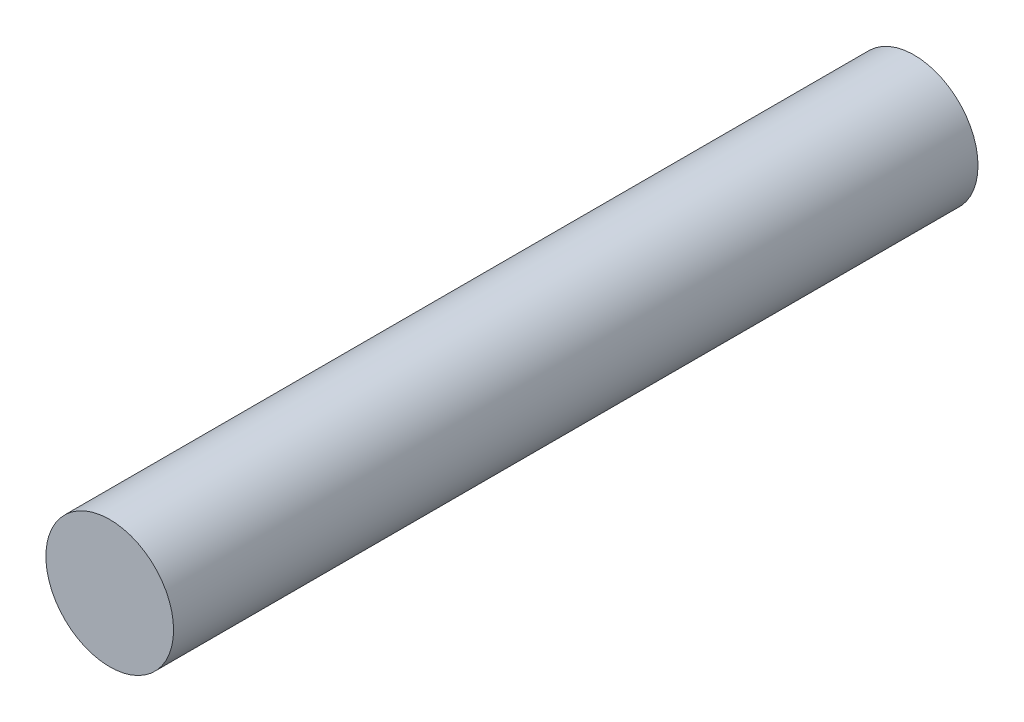
from build123d import *

# Parameters (mm, degrees)
SKETCH1_R           = 2.5
BOSS_EXTRUDE1_DEPTH = 31.5


with BuildPart() as part:
    # Sketch1 → Boss-Extrude1 (new body)
    with BuildSketch(Plane.XY):
        Circle(SKETCH1_R)
    extrude(amount=BOSS_EXTRUDE1_DEPTH)


solid = part.part
